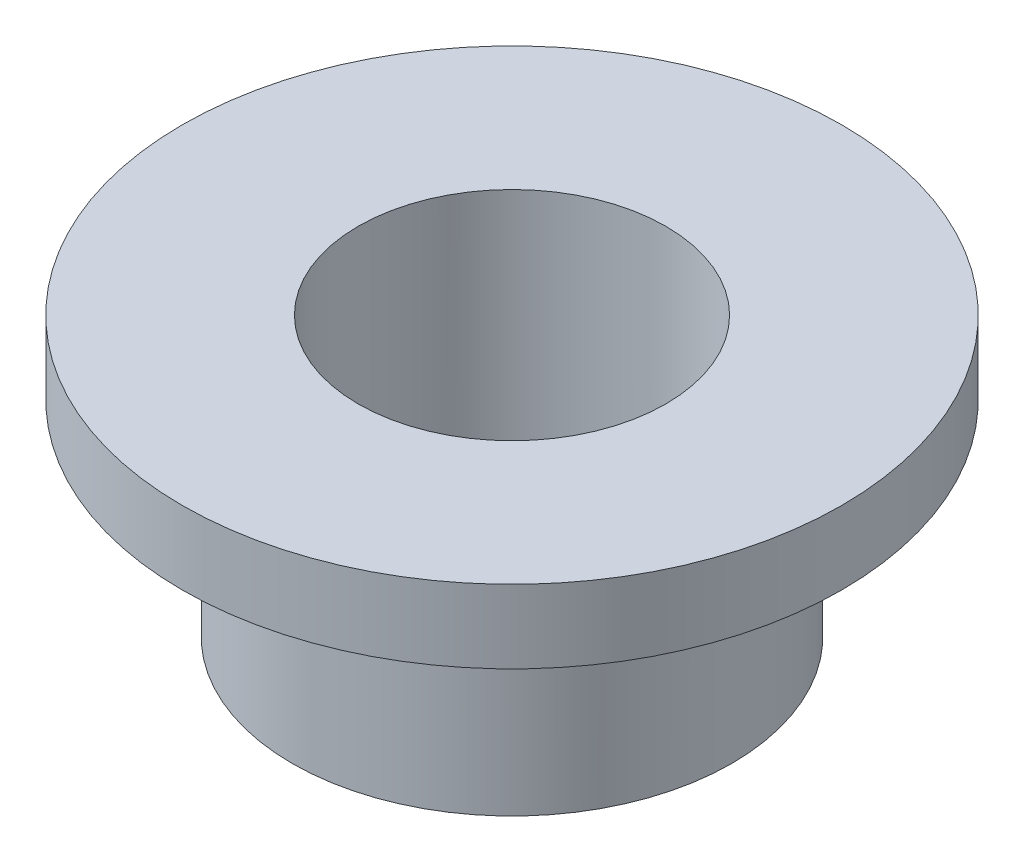
from build123d import *

# Parameters (mm, degrees)
SKETCH_1_R      = 4.5
SKETCH_1_R_2    = 2.1
EXTRUDE_1_DEPTH = 1
SKETCH_2_R      = 3
SKETCH_2_R_2    = 2.1
EXTRUDE_2_DEPTH = 2.8


with BuildPart() as part:
    # 草图1 → 凸台-拉伸1 (new body)
    with BuildSketch(Plane(origin=(0, 0, 0), x_dir=(1, 0, 0), z_dir=(0, 1, 0))):
        Circle(SKETCH_1_R)
        Circle(SKETCH_1_R_2, mode=Mode.SUBTRACT)
    extrude(amount=EXTRUDE_1_DEPTH)

    # 草图2 → 凸台-拉伸2 (add)
    with BuildSketch(Plane.XZ):
        Circle(SKETCH_2_R)
        Circle(SKETCH_2_R_2, mode=Mode.SUBTRACT)
    extrude(amount=EXTRUDE_2_DEPTH)


solid = part.part
